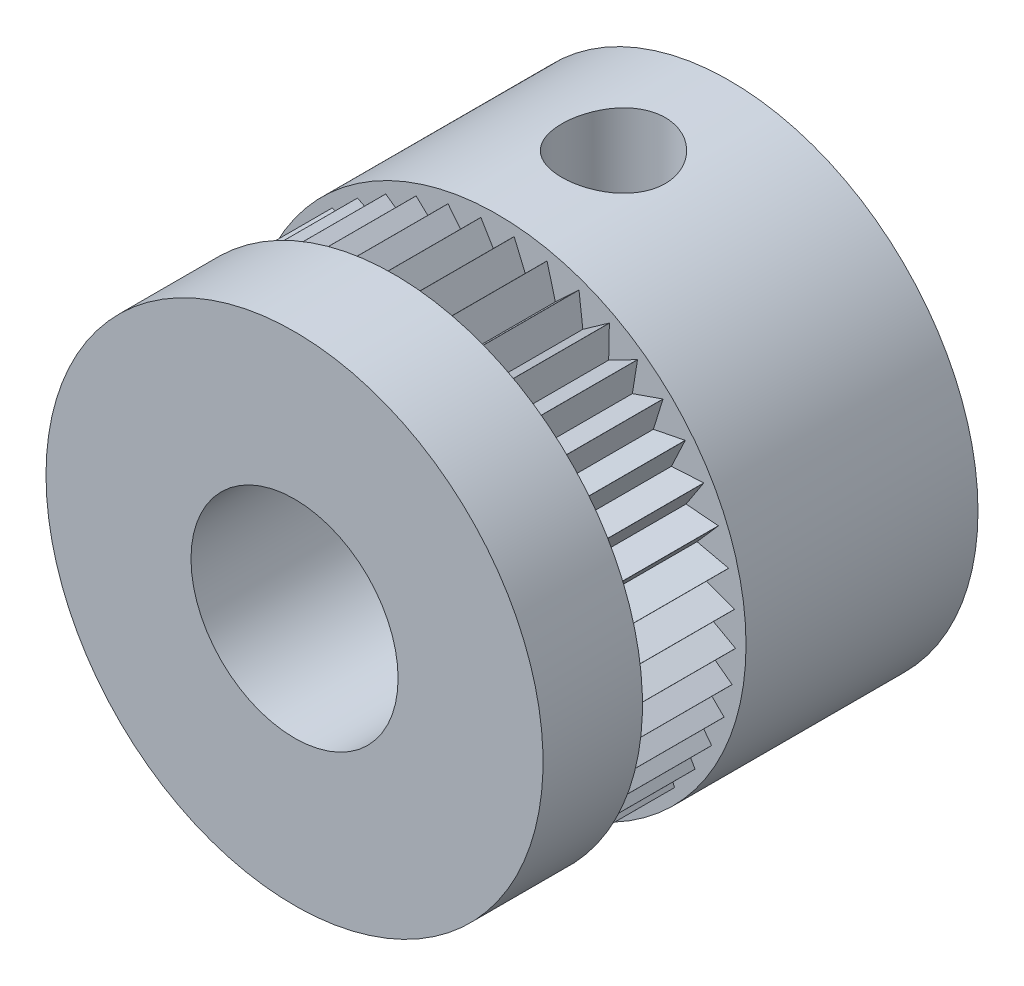
from build123d import *

# Parameters (mm, degrees)
CROQUIS1_R                                     = 6
CROQUIS1_R_2                                   = 2.5
SALIENTE_EXTRUIR1_DEPTH                        = 10.5
CROQUIS2_W                                     = 0.25
CROQUIS2_H                                     = 2.5
CORTAR_EXTRUIR1_DEPTH                          = 2.5
MATRIZC1_COUNT                                 = 45
PERFORADOR_PARA_ROSCAR_PARA_MACHO_DE_ROS_REACH = 19.037
PERFORADOR_PARA_ROSCAR_PARA_MACHO_DE_2_R       = 1.25


with BuildPart() as part:
    # Croquis1 → Saliente-Extruir1 (new body)
    with BuildSketch(Plane.XY):
        with Locations(Location((0, 0, 0), (0, 0, 180))):
            Circle(CROQUIS1_R)
        with Locations(Location((0, 0, 0), (0, 0, 180))):
            Circle(CROQUIS1_R_2, mode=Mode.SUBTRACT)
    extrude(amount=SALIENTE_EXTRUIR1_DEPTH)

    # Croquis2 → Cortar-Revolución1 (revolve, cut)
    with BuildSketch(Plane(origin=(0, 0, 0), x_dir=(1, 0, 0), z_dir=(0, 1, 0)), mode=Mode.PRIVATE) as cortar_revoluci_n1_sk:
        with Locations((5.875, -6.85)):
            Rectangle(CROQUIS2_W, CROQUIS2_H)
    revolve(cortar_revoluci_n1_sk.sketch.rotate(Axis((0, 0, 10.5), (0, 0, -1)), 180), axis=Axis((0, 0, 10.5), (0, 0, -1)), mode=Mode.SUBTRACT)

    # Croquis3 → Cortar-Extruir1 (cut)
    with BuildSketch(Plane(origin=(0, 0, 8.1), x_dir=(-1, 0, 0), z_dir=(0, 0, -1))):
        with BuildLine():
            Line((-0.4, 5.736070083), (0, 5.064736343))
            Line((0, 5.064736343), (0.4, 5.736070083))
            ThreePointArc((0.4, 5.736070083), (0, 5.75), (-0.4, 5.736070083))
        make_face()
    cortar_extruir1 = extrude(amount=CORTAR_EXTRUIR1_DEPTH, mode=Mode.SUBTRACT)

    # MatrizC1: Cortar-Extruir1 ×45 about axis
    matrizc1_axis = Axis((0, 0, 0), (0, 0, 1))
    for i in range(1, MATRIZC1_COUNT):
        add(cortar_extruir1.rotate(matrizc1_axis, i * 360 / MATRIZC1_COUNT), mode=Mode.SUBTRACT)

    # Perforador para roscar para macho de 2 → Perforador para roscar para macho de roscar para M31 (cut, up to next)
    with BuildSketch(Plane(origin=(0, 6, 0), x_dir=(1, 0, 0), z_dir=(0, 1, 0)), mode=Mode.PRIVATE) as perforador_para_roscar_para_macho_de_ros_sk1:
        with Locations((0, -2.8)):
            Circle(PERFORADOR_PARA_ROSCAR_PARA_MACHO_DE_2_R)
    perforador_para_roscar_para_macho_de_ros_tool1 = extrude(perforador_para_roscar_para_macho_de_ros_sk1.sketch, amount=-PERFORADOR_PARA_ROSCAR_PARA_MACHO_DE_ROS_REACH, mode=Mode.PRIVATE) & part.part
    add(perforador_para_roscar_para_macho_de_ros_tool1.solids().sort_by_distance((0, 6, 2.8))[0], mode=Mode.SUBTRACT)


solid = part.part
